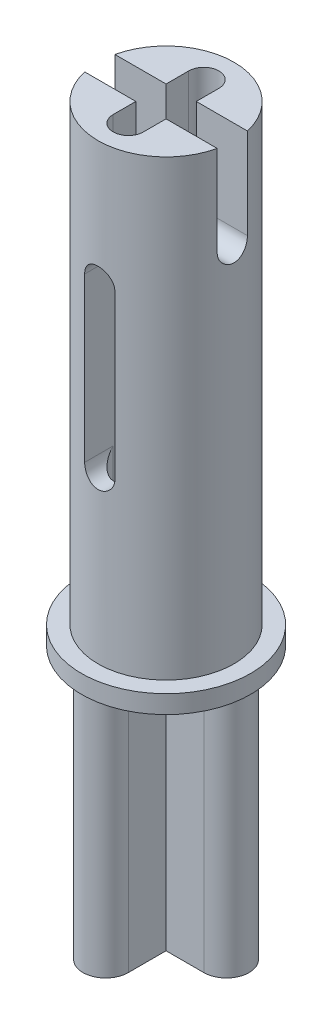
from build123d import *

# Parameters (mm, degrees)
SKETCH1_R           = 2.25
BOSS_EXTRUDE1_DEPTH = 15
SKETCH2_R           = 2.8
BOSS_EXTRUDE2_DEPTH = 0.6
CUT_EXTRUDE1_DEPTH  = 6.05
CUT_EXTRUDE5_DEPTH  = 6.05
CUT_EXTRUDE6_DEPTH  = 100
SKETCH11_W          = 1.5
SKETCH11_H          = 1.5
BOSS_EXTRUDE3_DEPTH = 8


with BuildPart() as part:
    # Sketch1 → Boss-Extrude1 (new body)
    with BuildSketch(Plane(origin=(0, 0, 0), x_dir=(1, 0, 0), z_dir=(0, 1, 0))):
        Circle(SKETCH1_R)
    extrude(amount=BOSS_EXTRUDE1_DEPTH)

    # Sketch2 → Boss-Extrude2 (add)
    with BuildSketch(Plane.XZ):
        Circle(SKETCH2_R)
    extrude(amount=BOSS_EXTRUDE2_DEPTH)

    # Sketch3 → Cut-Extrude1 (cut, through all)
    with BuildSketch(Plane.ZY.offset(2.25)):
        with BuildLine():
            Line((-0.5, 12), (-0.5, 15))
            ThreePointArc((-0.5, 15), (0, 15.5), (0.5, 15))
            Line((0.5, 15), (0.5, 12))
            ThreePointArc((0.5, 12), (0, 11.5), (-0.5, 12))
        make_face()
    extrude(amount=-CUT_EXTRUDE1_DEPTH, mode=Mode.SUBTRACT)

    # Sketch6 → Cut-Extrude5 (cut, through all)
    with BuildSketch(Plane.XY.offset(2.25)):
        with BuildLine():
            Line((-0.5, 5.5), (-0.5, 10.9))
            ThreePointArc((-0.5, 10.9), (0, 11.4), (0.5, 10.9))
            Line((0.5, 10.9), (0.5, 5.5))
            ThreePointArc((0.5, 5.5), (0, 5), (-0.5, 5.5))
        make_face()
    extrude(amount=-CUT_EXTRUDE5_DEPTH, mode=Mode.SUBTRACT)

    # Sketch8 → Cut-Extrude6 (cut)
    with BuildSketch(Plane(origin=(0, 100, 0), x_dir=(1, 0, 0), z_dir=(0, 1, 0))):
        with BuildLine():
            Line((0.5, 1.25), (0.5, -1.25))
            ThreePointArc((0.5, -1.25), (0, -1.75), (-0.5, -1.25))
            Line((-0.5, -1.25), (-0.5, 1.25))
            ThreePointArc((-0.5, 1.25), (0, 1.75), (0.5, 1.25))
        make_face()
    extrude(amount=-CUT_EXTRUDE6_DEPTH, mode=Mode.SUBTRACT)

    # Sketch11 → Boss-Extrude3 (add)
    with BuildSketch(Plane.XZ.offset(0.6)):
        with BuildLine():
            Line((-0.75, 2), (-0.75, 0.75))
            Line((-0.75, 0.75), (0.75, 0.75))
            Line((0.75, 0.75), (0.75, 2))
            ThreePointArc((0.75, 2), (0, 2.75), (-0.75, 2))
        make_face()
        Rectangle(SKETCH11_W, SKETCH11_H)
        with BuildLine():
            Line((0.75, 0.75), (0.75, -0.75))
            Line((0.75, -0.75), (2, -0.75))
            ThreePointArc((2, -0.75), (2.75, 0), (2, 0.75))
            Line((2, 0.75), (0.75, 0.75))
        make_face()
        with BuildLine():
            Line((-2, -0.75), (-0.75, -0.75))
            Line((-0.75, -0.75), (-0.75, 0.75))
            Line((-0.75, 0.75), (-2, 0.75))
            ThreePointArc((-2, 0.75), (-2.75, 0), (-2, -0.75))
        make_face()
        with BuildLine():
            Line((-0.75, -0.75), (-0.75, -2))
            ThreePointArc((-0.75, -2), (0, -2.75), (0.75, -2))
            Line((0.75, -2), (0.75, -0.75))
            Line((0.75, -0.75), (-0.75, -0.75))
        make_face()
    extrude(amount=BOSS_EXTRUDE3_DEPTH)


solid = part.part
